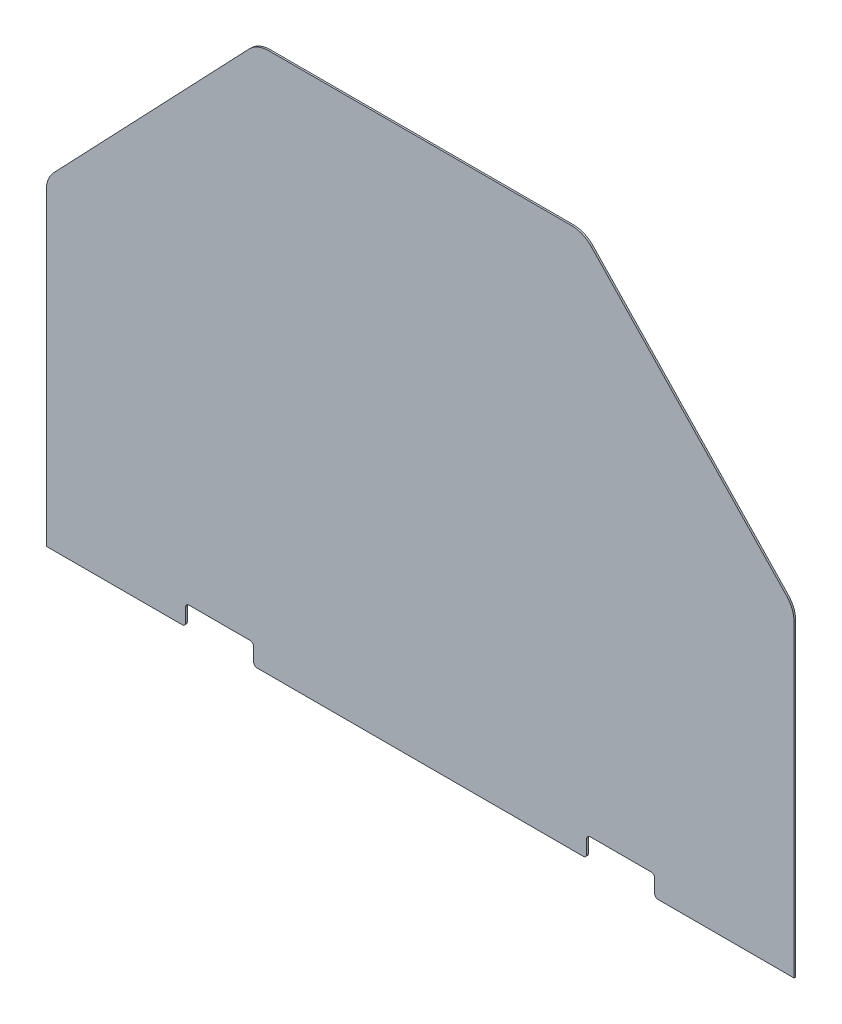
from build123d import *

# Parameters (mm, degrees)
BOSS_EXTRUDE1_DEPTH = 3.175
FILLET2_R           = 50.8
SKETCH2_W           = 127
SKETCH2_H           = 38.1
CUT_EXTRUDE1_DEPTH  = 4.175
FILLET3_R           = 6.35


with BuildPart() as part:
    # Sketch1 → Boss-Extrude1 (new body)
    with BuildSketch(Plane.XY):
        Polygon((-304.8, 1009.65), (304.8, 1009.65), (698.5, 596.9), (698.5, 0), (-698.5, 0), (-698.5, 596.9), align=None)
    extrude(amount=BOSS_EXTRUDE1_DEPTH)

    # Fillet2
    fillet2_edges = [part.edges().sort_by_distance(p)[0] for p in [
        (698.5, 596.9, 1.5875),
        (-698.5, 596.9, 1.5875),
        (-304.8, 1009.65, 1.5875),
        (304.8, 1009.65, 1.5875),
    ]]
    fillet(fillet2_edges, radius=FILLET2_R)

    # Sketch2 → Cut-Extrude1 (cut, through all)
    with BuildSketch(Plane(origin=(0, 0, 0), x_dir=(-1, 0, 0), z_dir=(0, 0, -1))):
        with Locations((374.65, 19.05)):
            Rectangle(SKETCH2_W, SKETCH2_H)
        with Locations((-374.65, 19.05)):
            Rectangle(SKETCH2_W, SKETCH2_H)
    extrude(amount=-CUT_EXTRUDE1_DEPTH, mode=Mode.SUBTRACT)

    # Fillet3
    fillet3_edges = [part.edges().sort_by_distance(p)[0] for p in [
        (-311.15, 0, 1.5875),
        (-311.15, 38.1, 1.5875),
        (-438.15, 38.1, 1.5875),
        (-438.15, 0, 1.5875),
        (311.15, 0, 1.5875),
        (438.15, 0, 1.5875),
        (438.15, 38.1, 1.5875),
        (311.15, 38.1, 1.5875),
    ]]
    fillet(fillet3_edges, radius=FILLET3_R)


solid = part.part
